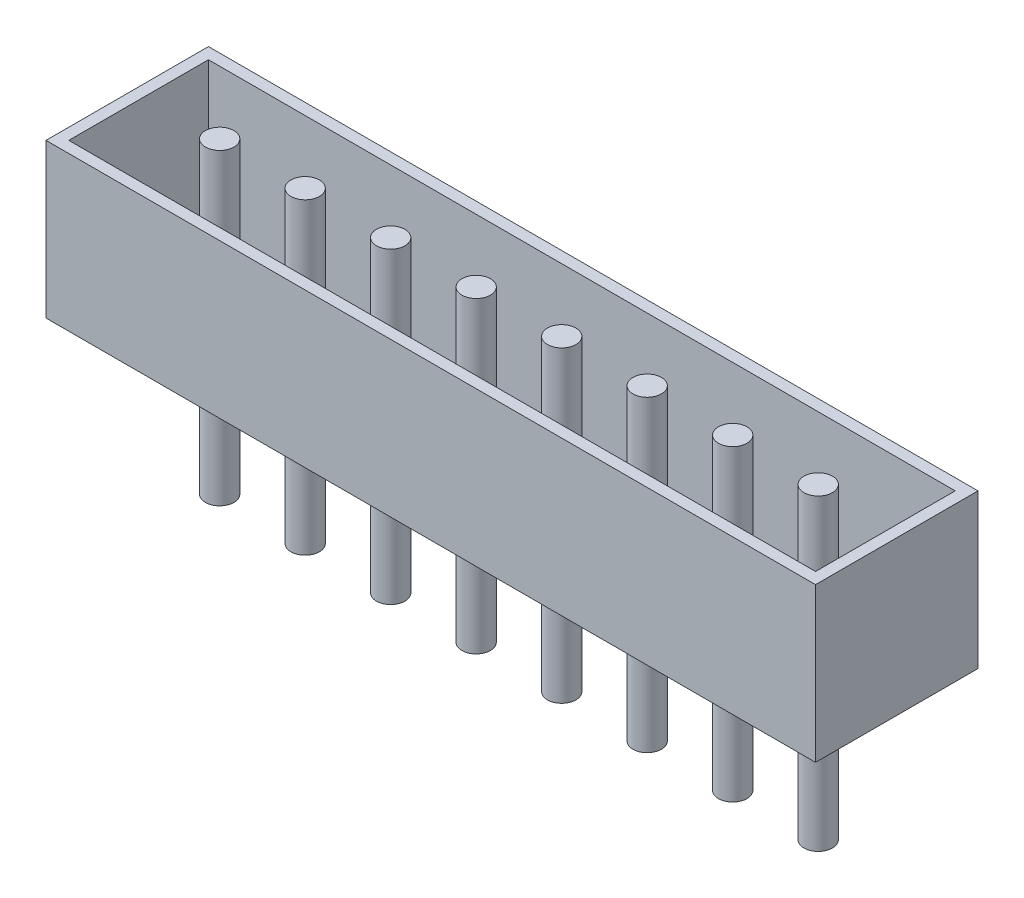
from build123d import *

# Parameters (mm, degrees)
SKETCH1_R             = 0.25
BOSS_EXTRUDE1_DEPTH   = 2.7
BOSS_EXTRUDE1_2_DEPTH = 2.7
BOSS_EXTRUDE1_3_DEPTH = 2.7
BOSS_EXTRUDE1_4_DEPTH = 2.7
BOSS_EXTRUDE1_5_DEPTH = 2.7
BOSS_EXTRUDE1_6_DEPTH = 2.7
BOSS_EXTRUDE1_7_DEPTH = 2.7
BOSS_EXTRUDE1_8_DEPTH = 2.7
SKETCH1_7_W           = 13.5
SKETCH1_7_H           = 2.85
SKETCH1_7_W_2         = 13.1
SKETCH1_7_H_2         = 2.45
BOSS_EXTRUDE3_DEPTH   = 2.7
BOSS_EXTRUDE4_START   = 0.2
SKETCH1_8_W           = 13.1
SKETCH1_8_H           = 2.45
SKETCH1_8_R           = 0.25
BOSS_EXTRUDE4_DEPTH   = 0.2
BOSS_EXTRUDE5_START   = 2.7
SKETCH1_9_R           = 0.25
BOSS_EXTRUDE5_DEPTH   = 2.7


with BuildPart() as part:
    # Sketch1 → Boss-Extrude1 (new body)
    with BuildSketch(Plane(origin=(0, 0, 0), x_dir=(1, 0, 0), z_dir=(0, 1, 0))):
        with Locations((-3.403301887, 0.02370283)):
            Circle(SKETCH1_R)
    extrude(amount=-BOSS_EXTRUDE1_DEPTH)



with BuildPart() as body_2:
    # Sketch1 → Boss-Extrude1 2 (new body)
    with BuildSketch(Plane(origin=(0, 0, 0), x_dir=(1, 0, 0), z_dir=(0, 1, 0))):
        with Locations((-1.903301887, 0.02370283)):
            Circle(SKETCH1_R)
    extrude(amount=-BOSS_EXTRUDE1_2_DEPTH)


with BuildPart() as body_3:
    # Sketch1 → Boss-Extrude1 3 (new body)
    with BuildSketch(Plane(origin=(0, 0, 0), x_dir=(1, 0, 0), z_dir=(0, 1, 0))):
        with Locations((-0.403301887, 0.02370283)):
            Circle(SKETCH1_R)
    extrude(amount=-BOSS_EXTRUDE1_3_DEPTH)


with BuildPart() as body_4:
    # Sketch1 → Boss-Extrude1 4 (new body)
    with BuildSketch(Plane(origin=(0, 0, 0), x_dir=(1, 0, 0), z_dir=(0, 1, 0))):
        with Locations((1.096698113, 0.02370283)):
            Circle(SKETCH1_R)
    extrude(amount=-BOSS_EXTRUDE1_4_DEPTH)


with BuildPart() as body_5:
    # Sketch1 → Boss-Extrude1 5 (new body)
    with BuildSketch(Plane(origin=(0, 0, 0), x_dir=(1, 0, 0), z_dir=(0, 1, 0))):
        with Locations((2.596698113, 0.02370283)):
            Circle(SKETCH1_R)
    extrude(amount=-BOSS_EXTRUDE1_5_DEPTH)


with BuildPart() as body_6:
    # Sketch1 → Boss-Extrude1 6 (new body)
    with BuildSketch(Plane(origin=(0, 0, 0), x_dir=(1, 0, 0), z_dir=(0, 1, 0))):
        with Locations((4.096698113, 0.02370283)):
            Circle(SKETCH1_R)
    extrude(amount=-BOSS_EXTRUDE1_6_DEPTH)


with BuildPart() as body_7:
    # Sketch1 → Boss-Extrude1 7 (new body)
    with BuildSketch(Plane(origin=(0, 0, 0), x_dir=(1, 0, 0), z_dir=(0, 1, 0))):
        with Locations((5.596698113, 0.02370283)):
            Circle(SKETCH1_R)
    extrude(amount=-BOSS_EXTRUDE1_7_DEPTH)


with BuildPart() as body_8:
    # Sketch1 → Boss-Extrude1 8 (new body)
    with BuildSketch(Plane(origin=(0, 0, 0), x_dir=(1, 0, 0), z_dir=(0, 1, 0))):
        with Locations((7.096698113, 0.02370283)):
            Circle(SKETCH1_R)
    extrude(amount=-BOSS_EXTRUDE1_8_DEPTH)


with BuildPart() as body_9:
    # Sketch1_7 → Boss-Extrude3 (new body)
    with BuildSketch(Plane(origin=(0, 0, 0), x_dir=(1, 0, 0), z_dir=(0, 1, 0))):
        with Locations((1.846698113, -0.098128497)):
            Rectangle(SKETCH1_7_W, SKETCH1_7_H)
        with Locations((1.846698113, -0.098128497)):
            Rectangle(SKETCH1_7_W_2, SKETCH1_7_H_2, mode=Mode.SUBTRACT)
    extrude(amount=BOSS_EXTRUDE3_DEPTH)

    # Sketch1_8 → Boss-Extrude4 (add)
    with BuildSketch(Plane(origin=(0, 0, 0), x_dir=(1, 0, 0), z_dir=(0, 1, 0)).offset(BOSS_EXTRUDE4_START)):
        with Locations((1.846698113, -0.098128497)):
            Rectangle(SKETCH1_8_W, SKETCH1_8_H)
        with Locations((-3.403301887, 0.02370283)):
            Circle(SKETCH1_8_R, mode=Mode.SUBTRACT)
        with Locations((-1.903301887, 0.02370283)):
            Circle(SKETCH1_8_R, mode=Mode.SUBTRACT)
        with Locations((-0.403301887, 0.02370283)):
            Circle(SKETCH1_8_R, mode=Mode.SUBTRACT)
        with Locations((1.096698113, 0.02370283)):
            Circle(SKETCH1_8_R, mode=Mode.SUBTRACT)
        with Locations((2.596698113, 0.02370283)):
            Circle(SKETCH1_8_R, mode=Mode.SUBTRACT)
        with Locations((4.096698113, 0.02370283)):
            Circle(SKETCH1_8_R, mode=Mode.SUBTRACT)
        with Locations((5.596698113, 0.02370283)):
            Circle(SKETCH1_8_R, mode=Mode.SUBTRACT)
        with Locations((7.096698113, 0.02370283)):
            Circle(SKETCH1_8_R, mode=Mode.SUBTRACT)
    extrude(amount=-BOSS_EXTRUDE4_DEPTH)


with BuildPart() as part_1:
    add(part.part)

    add(body_2.part)  # Boss-Extrude5 merges body 2

    add(body_3.part)  # Boss-Extrude5 merges body 3

    add(body_4.part)  # Boss-Extrude5 merges body 4

    add(body_5.part)  # Boss-Extrude5 merges body 5

    add(body_6.part)  # Boss-Extrude5 merges body 6

    add(body_7.part)  # Boss-Extrude5 merges body 7

    add(body_8.part)  # Boss-Extrude5 merges body 8

    add(body_9.part)  # Boss-Extrude5 merges body 9
    # Sketch1_9 → Boss-Extrude5 (add)
    with BuildSketch(Plane(origin=(0, 0, 0), x_dir=(1, 0, 0), z_dir=(0, 1, 0)).offset(BOSS_EXTRUDE5_START)):
        with Locations((-3.403301887, 0.02370283)):
            Circle(SKETCH1_9_R)
        with Locations((-1.903301887, 0.02370283)):
            Circle(SKETCH1_9_R)
        with Locations((-0.403301887, 0.02370283)):
            Circle(SKETCH1_9_R)
        with Locations((1.096698113, 0.02370283)):
            Circle(SKETCH1_9_R)
        with Locations((2.596698113, 0.02370283)):
            Circle(SKETCH1_9_R)
        with Locations((4.096698113, 0.02370283)):
            Circle(SKETCH1_9_R)
        with Locations((5.596698113, 0.02370283)):
            Circle(SKETCH1_9_R)
        with Locations((7.096698113, 0.02370283)):
            Circle(SKETCH1_9_R)
    extrude(amount=-BOSS_EXTRUDE5_DEPTH)


solid = part_1.part
